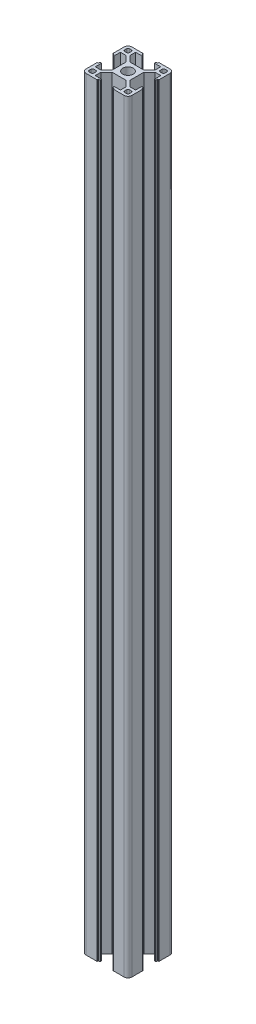
from build123d import *

# Parameters (mm, degrees)
SKETCH_3_R      = 3.4
EXTRUDE_1_DEPTH = 500


with BuildPart() as part:
    # 草图3 → 凸台-拉伸1 (new body)
    with BuildSketch(Plane(origin=(0, 0, 0), x_dir=(1, 0, 0), z_dir=(0, 1, 0))):
        with BuildLine():
            Line((-15, -12.5), (-15, -5.4))
            ThreePointArc((-15, -5.4), (-14.941421356, -5.258578644), (-14.8, -5.2))
            Line((-14.8, -5.2), (-14.4, -5.2))
            ThreePointArc((-14.4, -5.2), (-14.258578644, -5.141421356), (-14.2, -5))
            Line((-14.2, -5), (-14.2, -4.3))
            ThreePointArc((-14.2, -4.3), (-14.141421356, -4.158578644), (-14, -4.1))
            Line((-14, -4.1), (-13.2, -4.1))
            Line((-13.2, -4.1), (-13.2, -8.25))
            Line((-13.2, -8.25), (-9.522792206, -8.25))
            Line((-9.522792206, -8.25), (-5.8, -4.527207794))
            Line((-5.8, -4.527207794), (-5.8, 4.527207794))
            Line((-5.8, 4.527207794), (-9.522792206, 8.25))
            Line((-9.522792206, 8.25), (-13.2, 8.25))
            Line((-13.2, 8.25), (-13.2, 4.1))
            Line((-13.2, 4.1), (-14, 4.1))
            ThreePointArc((-14, 4.1), (-14.141421356, 4.158578644), (-14.2, 4.3))
            Line((-14.2, 4.3), (-14.2, 5))
            ThreePointArc((-14.2, 5), (-14.258578644, 5.141421356), (-14.4, 5.2))
            Line((-14.4, 5.2), (-14.8, 5.2))
            ThreePointArc((-14.8, 5.2), (-14.941421356, 5.258578644), (-15, 5.4))
            Line((-15, 5.4), (-15, 12.5))
            ThreePointArc((-15, 12.5), (-14.267766953, 14.267766953), (-12.5, 15))
            Line((-12.5, 15), (-5.4, 15))
            ThreePointArc((-5.4, 15), (-5.258578644, 14.941421356), (-5.2, 14.8))
            Line((-5.2, 14.8), (-5.2, 14.4))
            ThreePointArc((-5.2, 14.4), (-5.141421356, 14.258578644), (-5, 14.2))
            Line((-5, 14.2), (-4.3, 14.2))
            ThreePointArc((-4.3, 14.2), (-4.158578644, 14.141421356), (-4.1, 14))
            Line((-4.1, 14), (-4.1, 13.2))
            Line((-4.1, 13.2), (-8.25, 13.2))
            Line((-8.25, 13.2), (-8.25, 9.522792206))
            Line((-8.25, 9.522792206), (-4.527207794, 5.8))
            Line((-4.527207794, 5.8), (4.527207794, 5.8))
            Line((4.527207794, 5.8), (8.25, 9.522792206))
            Line((8.25, 9.522792206), (8.25, 13.2))
            Line((8.25, 13.2), (4.1, 13.2))
            Line((4.1, 13.2), (4.1, 14))
            ThreePointArc((4.1, 14), (4.158578644, 14.141421356), (4.3, 14.2))
            Line((4.3, 14.2), (5, 14.2))
            ThreePointArc((5, 14.2), (5.141421356, 14.258578644), (5.2, 14.4))
            Line((5.2, 14.4), (5.2, 14.8))
            ThreePointArc((5.2, 14.8), (5.258578644, 14.941421356), (5.4, 15))
            Line((5.4, 15), (12.5, 15))
            ThreePointArc((12.5, 15), (14.267766953, 14.267766953), (15, 12.5))
            Line((15, 12.5), (15, 5.4))
            ThreePointArc((15, 5.4), (14.941421356, 5.258578644), (14.8, 5.2))
            Line((14.8, 5.2), (14.4, 5.2))
            ThreePointArc((14.4, 5.2), (14.258578644, 5.141421356), (14.2, 5))
            Line((14.2, 5), (14.2, 4.3))
            ThreePointArc((14.2, 4.3), (14.141421356, 4.158578644), (14, 4.1))
            Line((14, 4.1), (13.2, 4.1))
            Line((13.2, 4.1), (13.2, 8.25))
            Line((13.2, 8.25), (9.522792206, 8.25))
            Line((9.522792206, 8.25), (5.8, 4.527207794))
            Line((5.8, 4.527207794), (5.8, -4.527207794))
            Line((5.8, -4.527207794), (9.522792206, -8.25))
            Line((9.522792206, -8.25), (13.2, -8.25))
            Line((13.2, -8.25), (13.2, -4.1))
            Line((13.2, -4.1), (14, -4.1))
            ThreePointArc((14, -4.1), (14.141421356, -4.158578644), (14.2, -4.3))
            Line((14.2, -4.3), (14.2, -5))
            ThreePointArc((14.2, -5), (14.258578644, -5.141421356), (14.4, -5.2))
            Line((14.4, -5.2), (14.8, -5.2))
            ThreePointArc((14.8, -5.2), (14.941421356, -5.258578644), (15, -5.4))
            Line((15, -5.4), (15, -12.5))
            ThreePointArc((15, -12.5), (14.267766953, -14.267766953), (12.5, -15))
            Line((12.5, -15), (5.4, -15))
            ThreePointArc((5.4, -15), (5.258578644, -14.941421356), (5.2, -14.8))
            Line((5.2, -14.8), (5.2, -14.4))
            ThreePointArc((5.2, -14.4), (5.141421356, -14.258578644), (5, -14.2))
            Line((5, -14.2), (4.3, -14.2))
            ThreePointArc((4.3, -14.2), (4.158578644, -14.141421356), (4.1, -14))
            Line((4.1, -14), (4.1, -13.2))
            Line((4.1, -13.2), (8.25, -13.2))
            Line((8.25, -13.2), (8.25, -9.522792206))
            Line((8.25, -9.522792206), (4.527207794, -5.8))
            Line((4.527207794, -5.8), (-4.527207794, -5.8))
            Line((-4.527207794, -5.8), (-8.25, -9.522792206))
            Line((-8.25, -9.522792206), (-8.25, -13.2))
            Line((-8.25, -13.2), (-4.1, -13.2))
            Line((-4.1, -13.2), (-4.1, -14))
            ThreePointArc((-4.1, -14), (-4.158578644, -14.141421356), (-4.3, -14.2))
            Line((-4.3, -14.2), (-5, -14.2))
            ThreePointArc((-5, -14.2), (-5.141421356, -14.258578644), (-5.2, -14.4))
            Line((-5.2, -14.4), (-5.2, -14.8))
            ThreePointArc((-5.2, -14.8), (-5.258578644, -14.941421356), (-5.4, -15))
            Line((-5.4, -15), (-12.5, -15))
            ThreePointArc((-12.5, -15), (-14.267766953, -14.267766953), (-15, -12.5))
        make_face()
        Circle(SKETCH_3_R, mode=Mode.SUBTRACT)
        with BuildLine():
            Line((-13.2, -12.2), (-13.2, -11.05))
            ThreePointArc((-13.2, -11.05), (-12.907106781, -10.342893219), (-12.2, -10.05))
            Line((-12.2, -10.05), (-11.05, -10.05))
            ThreePointArc((-11.05, -10.05), (-10.342893219, -10.342893219), (-10.05, -11.05))
            Line((-10.05, -11.05), (-10.05, -12.2))
            ThreePointArc((-10.05, -12.2), (-10.342893219, -12.907106781), (-11.05, -13.2))
            Line((-11.05, -13.2), (-12.2, -13.2))
            ThreePointArc((-12.2, -13.2), (-12.907106781, -12.907106781), (-13.2, -12.2))
        make_face(mode=Mode.SUBTRACT)
        with BuildLine():
            Line((-10.05, 12.2), (-10.05, 11.05))
            ThreePointArc((-10.05, 11.05), (-10.342893219, 10.342893219), (-11.05, 10.05))
            Line((-11.05, 10.05), (-12.2, 10.05))
            ThreePointArc((-12.2, 10.05), (-12.907106781, 10.342893219), (-13.2, 11.05))
            Line((-13.2, 11.05), (-13.2, 12.2))
            ThreePointArc((-13.2, 12.2), (-12.907106781, 12.907106781), (-12.2, 13.2))
            Line((-12.2, 13.2), (-11.05, 13.2))
            ThreePointArc((-11.05, 13.2), (-10.342893219, 12.907106781), (-10.05, 12.2))
        make_face(mode=Mode.SUBTRACT)
        with BuildLine():
            Line((13.2, 12.2), (13.2, 11.05))
            ThreePointArc((13.2, 11.05), (12.907106781, 10.342893219), (12.2, 10.05))
            Line((12.2, 10.05), (11.05, 10.05))
            ThreePointArc((11.05, 10.05), (10.342893219, 10.342893219), (10.05, 11.05))
            Line((10.05, 11.05), (10.05, 12.2))
            ThreePointArc((10.05, 12.2), (10.342893219, 12.907106781), (11.05, 13.2))
            Line((11.05, 13.2), (12.2, 13.2))
            ThreePointArc((12.2, 13.2), (12.907106781, 12.907106781), (13.2, 12.2))
        make_face(mode=Mode.SUBTRACT)
        with BuildLine():
            Line((10.05, -12.2), (10.05, -11.05))
            ThreePointArc((10.05, -11.05), (10.342893219, -10.342893219), (11.05, -10.05))
            Line((11.05, -10.05), (12.2, -10.05))
            ThreePointArc((12.2, -10.05), (12.907106781, -10.342893219), (13.2, -11.05))
            Line((13.2, -11.05), (13.2, -12.2))
            ThreePointArc((13.2, -12.2), (12.907106781, -12.907106781), (12.2, -13.2))
            Line((12.2, -13.2), (11.05, -13.2))
            ThreePointArc((11.05, -13.2), (10.342893219, -12.907106781), (10.05, -12.2))
        make_face(mode=Mode.SUBTRACT)
    extrude(amount=EXTRUDE_1_DEPTH)


solid = part.part
